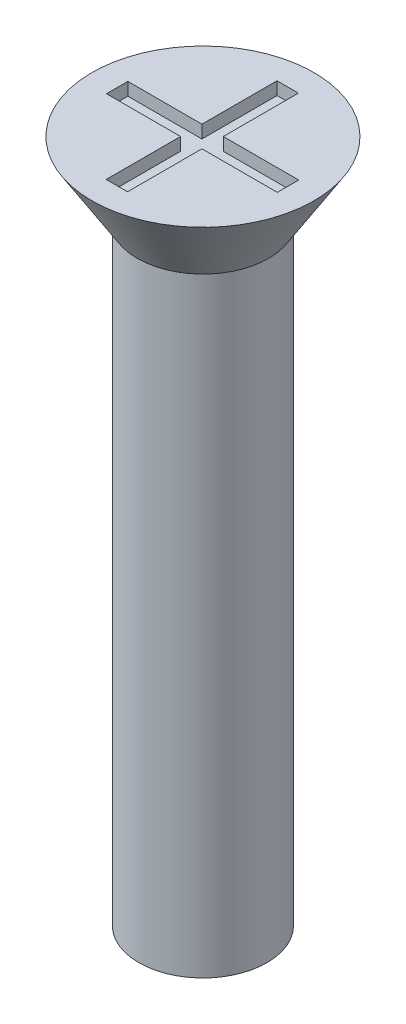
from build123d import *

# Parameters (mm, degrees)
SKETCH1_R           = 1.5
BOSS_EXTRUDE1_DEPTH = 16
SKETCH2_R           = 2.6
BOSS_EXTRUDE2_DEPTH = 1.7
BOSS_EXTRUDE2_TAPER = 32
SKETCH3_W           = 0.5
SKETCH3_H           = 1.758378485
SKETCH3_H_2         = 1.741621515
SKETCH3_W_2         = 1.734727157
SKETCH3_H_3         = 0.5
SKETCH3_W_3         = 1.765272843
CUT_EXTRUDE1_DEPTH  = 0.3


with BuildPart() as part:
    # Sketch1 → Boss-Extrude1 (new body)
    with BuildSketch(Plane(origin=(0, 0, 0), x_dir=(1, 0, 0), z_dir=(0, 1, 0))):
        Circle(SKETCH1_R)
    extrude(amount=BOSS_EXTRUDE1_DEPTH)

    # Sketch2 → Boss-Extrude2 (add)
    with BuildSketch(Plane(origin=(0, 16, 0), x_dir=(1, 0, 0), z_dir=(0, 1, 0))):
        Circle(SKETCH2_R)
    extrude(amount=-BOSS_EXTRUDE2_DEPTH, taper=BOSS_EXTRUDE2_TAPER)

    # Sketch3 → Cut-Extrude1 (cut)
    with BuildSketch(Plane(origin=(0, 16, 0), x_dir=(1, 0, 0), z_dir=(0, 1, 0))):
        with Locations((-0.015272843, 1.120810757)):
            Rectangle(SKETCH3_W, SKETCH3_H)
        with Locations((-0.015272843, -1.129189243)):
            Rectangle(SKETCH3_W, SKETCH3_H_2)
        with Locations((-1.132636421, -0.008378485)):
            Rectangle(SKETCH3_W_2, SKETCH3_H_3)
        with Locations((1.117363579, -0.008378485)):
            Rectangle(SKETCH3_W_3, SKETCH3_H_3)
        with Locations((-0.015272843, -0.008378485)):
            Rectangle(SKETCH3_W, SKETCH3_H_3)
    extrude(amount=-CUT_EXTRUDE1_DEPTH, mode=Mode.SUBTRACT)


solid = part.part
